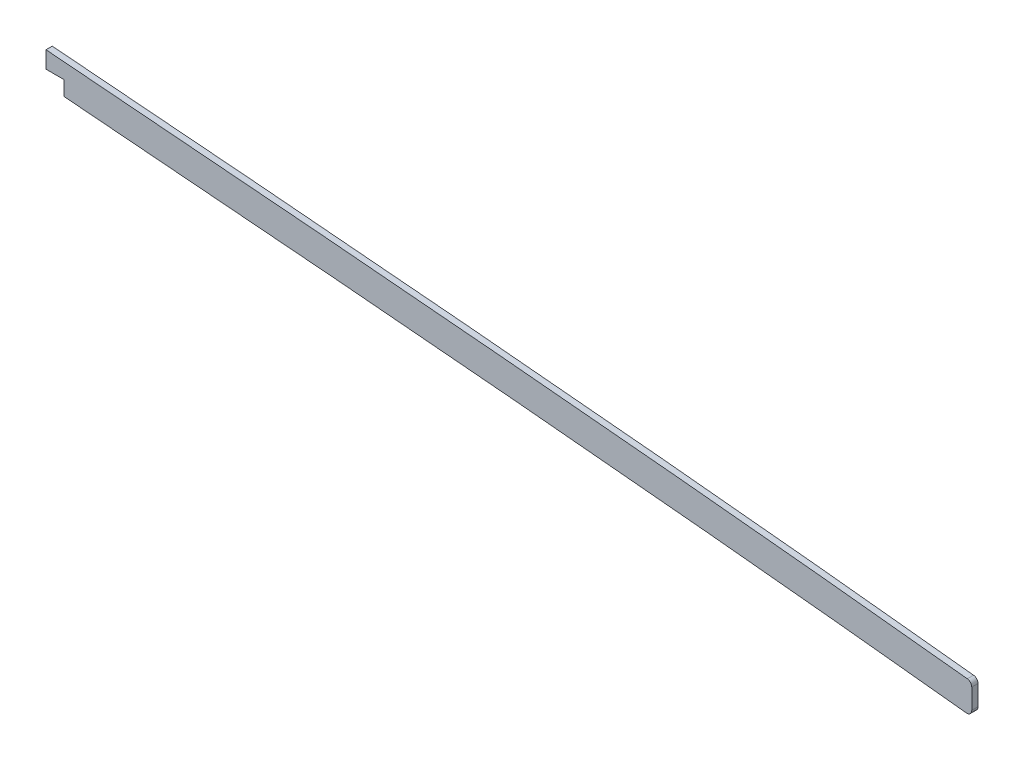
from build123d import *

# Parameters (mm, degrees)
BOSS_EXTRUDE1_DEPTH = 1.5875
FILLET1_R           = 2.54
CUT_EXTRUDE1_DEPTH  = 7.62


with BuildPart() as part:
    # Sketch2 → Boss-Extrude1 (new body, symmetric)
    with BuildSketch(Plane.XY):
        with BuildLine():
            add(Edge.make_bspline(
                [(825.5, 263.72872798), (833.004293944, 262.763036085), (840.535916247, 261.846014478), (848.126574562, 260.964164828), (892.90639318, 255.945629274), (937.686211733, 251.779150949), (973.452075064, 248.227669425), (1071.946672141, 239.051054038), (1170.441269319, 229.731506738), (1231.791940344, 224.503945813), (1324.899336146, 216.790627817), (1418.006730935, 209.040117978), (1449.742935921, 206.361809936), (1636.928606778, 190.521130342), (1824.114277635, 175.409157235), (1979.966947376, 164.299650253), (2156.268639429, 150.414433314), (2332.570330468, 133.857216402), (2354.212983157, 131.78508222), (2394.341467798, 127.847039259), (2434.469952439, 123.717187755), (2453.57670361, 121.704562273), (2472.669581058, 119.647220503), (2491.74, 117.547195763)],
                knots=[78.681340958, 78.681340958, 78.681340958, 78.681340958, 78.681340958, 78.681340958, 82.46579272, 82.46579272, 82.46579272, 100.7932901, 100.7932901, 100.7932901, 131.0989539, 131.0989539, 131.0989539, 146.7691983, 146.7691983, 146.7691983, 223.5339586, 223.5339586, 223.5339586, 233.9431167, 233.9431167, 233.9431167, 243.40815085, 243.40815085, 243.40815085, 243.40815085, 243.40815085, 243.40815085], degree=5))
            Line((825.5, 263.72872798), (825.5, 248.364439806))
            add(Edge.make_bspline(
                [(825.5, 248.364439806), (827.20768691, 248.14708351), (833.784664511, 247.321927102), (845.28106727, 245.953419483), (860.086531547, 244.295598067), (879.830703434, 242.186646028), (904.369967092, 239.698279806), (933.571022669, 236.832150625), (962.642718041, 234.023667741), (991.762593943, 231.241975908), (1021.072010315, 228.475862291), (1060.376437315, 224.796956681), (1109.513015577, 220.184378862), (1168.511190361, 214.817071985), (1227.500129793, 209.662054042), (1306.133167947, 203.021178328), (1404.361477105, 194.920725932), (1522.239851071, 184.918066624), (1640.182856491, 175.167007786), (1758.165352567, 165.757639485), (1876.155384769, 156.590937079), (1994.08749188, 147.453250142), (2092.268692061, 139.624216053), (2170.748029042, 133.079656729), (2219.771730977, 128.842227836), (2258.983988247, 125.347211495), (2288.379457536, 122.670854497), (2317.812243116, 119.931729386), (2347.551509172, 117.100365283), (2377.159899727, 114.21011853), (2406.469653851, 111.26896801), (2435.81832606, 108.240091266), (2464.242715806, 105.222889554), (2482.876892709, 103.192325927), (2491.74, 102.214848055)],
                knots=[78.875303138, 78.875303138, 78.875303138, 78.875303138, 79.386176103, 80.841530691, 82.29688528, 83.752239868, 86.662949044, 89.57365822, 92.484367397, 95.395076573, 98.305785749, 101.216494926, 107.037913278, 112.859331631, 118.680749984, 124.502168336, 136.145005042, 147.787841747, 159.430678452, 171.073515158, 182.716351863, 194.359188568, 206.002025273, 211.823443626, 217.644861979, 220.555571155, 223.466280331, 226.376989508, 229.287698684, 232.19840786, 235.109117037, 238.019826213, 240.930535389, 243.57402126, 243.57402126, 243.57402126, 243.57402126], degree=3))
            Line((2491.74, 102.214848055), (2491.74, 117.547195763))
        make_face()
    extrude(amount=BOSS_EXTRUDE1_DEPTH, both=True)

    # Fillet1
    fillet1_edges = [part.edges().sort_by_distance(p)[0] for p in [
        (2491.74, 102.214848055, -0.79375),
        (2491.74, 117.547195763, -0.79375),
        (825.5, 248.364439806, -0.79375),
        (825.5, 263.72872798, 0.79375),
    ]]
    fillet(fillet1_edges, radius=FILLET1_R)

    # Sketch3 → Cut-Extrude1 (cut)
    with BuildSketch(Plane.XY.offset(1.5875)):
        Polygon((2021.302635877, 160.549539386), (2021.302635877, 169.900353667), (799.626603734, 282.38943621), (799.626603734, 218.449722533), (2030.428965883, 140.193570719), (2030.428965883, 144.537877355), (2030.428965883, 151.973195802), (2021.302635877, 151.973195802), align=None)
    extrude(amount=-CUT_EXTRUDE1_DEPTH, mode=Mode.SUBTRACT)


solid = part.part
